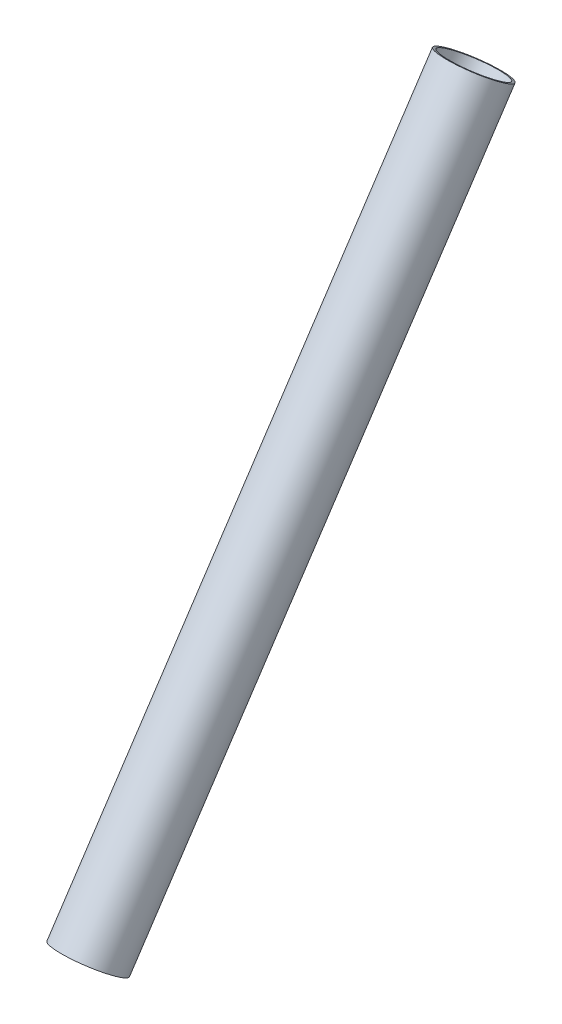
from build123d import *

# Parameters (mm, degrees)
SKETCH2_R           = 9.601199998
SKETCH2_R_2         = 8.813799998
BOSS_EXTRUDE1_DEPTH = 210.367126


with BuildPart() as part:
    # Sketch2 → Boss-Extrude1 (new body)
    with BuildSketch(Plane(origin=(0.316397262, -246.173121869, 163.806116137), x_dir=(-0.99999934, -0.000659664, 0.000940169), z_dir=(0.001070023, -0.832532279, 0.553975504))):
        with Locations((-29.441850098, -1529.592948735)):
            Circle(SKETCH2_R)
        with Locations((-29.441850098, -1529.592948735)):
            Circle(SKETCH2_R_2, mode=Mode.SUBTRACT)
    extrude(amount=BOSS_EXTRUDE1_DEPTH)


solid = part.part
